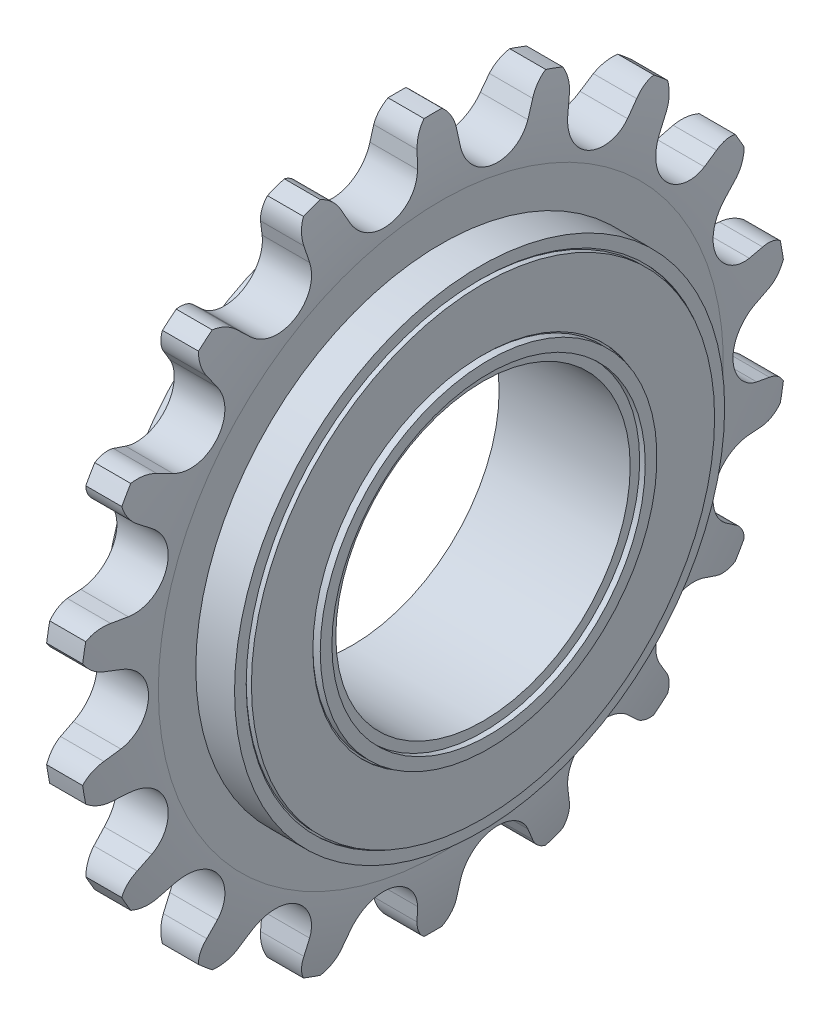
from build123d import *

# Parameters (mm, degrees)
BOSS_EXTRUDE1_DEPTH = 8.5
CIRPATTERN2_COUNT   = 18


with BuildPart() as part:
    # Sketch4 → Boss-Extrude1 (new body, symmetric)
    with BuildSketch(Plane(origin=(0, 0, 0), x_dir=(0, 0, -1), z_dir=(1, 0, 0))):
        with BuildLine():
            Line((-2.375769814, 35.55932462), (-2.179823405, 37.277194632))
            ThreePointArc((-2.179823405, 37.277194632), (-1.800513784, 38.489661275), (-0.999276737, 39.47554684))
            ThreePointArc((-0.999276737, 39.47554684), (0.000723495, 39.488192561), (1.000723263, 39.475510196))
            ThreePointArc((1.000723263, 39.475510196), (1.801395262, 38.48954341), (2.180257332, 37.277244072))
            Line((2.180257332, 37.277244072), (2.375655404, 35.560328787))
            ThreePointArc((2.375655404, 35.560328787), (3.436343004, 33.272091633), (5.655407289, 32.073408543))
            Line((5.655407289, 32.073408543), (0, 0))
            Line((0, 0), (-5.655407289, 32.073408543))
            ThreePointArc((-5.655407289, 32.073408543), (-3.436689249, 33.271723564), (-2.375769814, 35.55932462))
        make_face()
    boss_extrude1 = extrude(amount=BOSS_EXTRUDE1_DEPTH, both=True)

    # CirPattern2: Boss-Extrude1 ×18 about axis
    cirpattern2_axis = Axis((0, 0, 0), (1, 0, 0))
    for i in range(1, CIRPATTERN2_COUNT):
        add(boss_extrude1.rotate(cirpattern2_axis, i * 360 / CIRPATTERN2_COUNT))

    # Sketch6 → Cut-Revolve1 (revolve, cut)
    with BuildSketch(Plane.XY):
        with BuildLine():
            Line((-10, 39.488192568), (-10, 0))
            Line((-10, 0), (10, 0))
            Line((10, 0), (10, 39.488192568))
            Line((10, 39.488192568), (2.007683736, 39.488192568))
            ThreePointArc((2.007683736, 39.488192568), (2.663445117, 35.512058977), (2.8829, 31.488192568))
            Line((2.8829, 31.488192568), (2.8829, 27.3125))
            Line((2.8829, 27.3125), (7.2, 27.3125))
            Line((7.2, 27.3125), (7.2, 26.0125))
            Line((7.2, 26.0125), (7, 26.0125))
            Line((7, 26.0125), (7, 25.8125))
            Line((7, 25.8125), (7.58, 25.8125))
            Line((7.58, 25.8125), (7.58, 18.9625))
            Line((7.58, 18.9625), (7.38, 18.9625))
            Line((7.38, 18.9625), (7.38, 18.7625))
            Line((7.38, 18.7625), (8.2, 18.7625))
            Line((8.2, 18.7625), (8.2, 17.4625))
            Line((8.2, 17.4625), (7.58, 17.4625))
            Line((7.58, 17.4625), (7.58, 16.404166667))
            Line((7.58, 16.404166667), (-7.2, 16.404166667))
            Line((-7.2, 16.404166667), (-7.2, 18.9625))
            Line((-7.2, 18.9625), (-7.58, 18.9625))
            Line((-7.58, 18.9625), (-7.58, 25.8125))
            Line((-7.58, 25.8125), (-7, 25.8125))
            Line((-7, 25.8125), (-7, 26.0125))
            Line((-7, 26.0125), (-7.2, 26.0125))
            Line((-7.2, 26.0125), (-7.2, 27.3125))
            Line((-7.2, 27.3125), (-2.8829, 27.3125))
            Line((-2.8829, 27.3125), (-2.8829, 31.488192568))
            ThreePointArc((-2.8829, 31.488192568), (-2.663445117, 35.512058977), (-2.007683736, 39.488192568))
            Line((-2.007683736, 39.488192568), (-10, 39.488192568))
        make_face()
    revolve(axis=Axis((0, 0, 0), (1, 0, 0)), mode=Mode.SUBTRACT)

    # Sketch7 → Cut-Revolve2 (revolve, cut)
    with BuildSketch(Plane.XY):
        Polygon((-7.63, 17.27589746), (-8.141029035, 16.390769207), (-8.141029035, 16.304166667), (-7.018970965, 16.304166667), (-7.018970965, 16.390769207), (-7.53, 17.27589746), align=None)
    revolve(axis=Axis((0, 0, 0), (1, 0, 0)), mode=Mode.SUBTRACT)


solid = part.part
